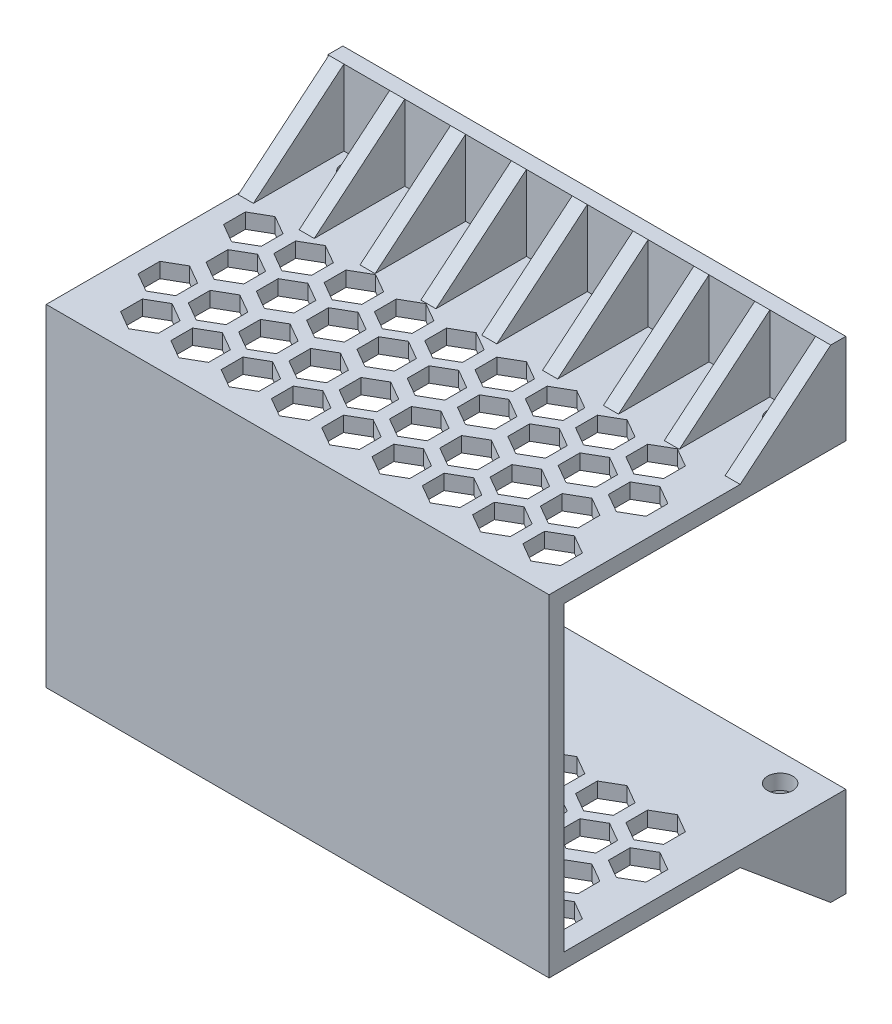
from build123d import *

# Parameters (mm, degrees)
SKETCH1_W                = 100
SKETCH1_H                = 60
BOSS_EXTRUDE1_DEPTH      = 3
SKETCH2_W                = 100
SKETCH2_H                = 3
BOSS_EXTRUDE2_DEPTH      = 53
BOSS_EXTRUDE2_DEPTH_BACK = 3
SKETCH3_W                = 100
SKETCH3_H                = 18
BOSS_EXTRUDE3_DEPTH      = 3
CUT_EXTRUDE1_DEPTH       = 82
BOSS_EXTRUDE4_DEPTH      = 3
SKETCH6_W                = 97
SKETCH6_H                = 18
BOSS_EXTRUDE5_DEPTH      = 3
LPATTERN4_COUNT          = 9
LPATTERN4_PITCH          = 12.1
SKETCH7_R                = 2.5
CUT_EXTRUDE2_DEPTH       = 82
SKETCH8_W                = 64.570177282
SKETCH8_H                = 59.777004532
CUT_EXTRUDE3_DEPTH       = 101


with BuildPart() as part:
    # Sketch1 → Boss-Extrude1 (new body)
    with BuildSketch(Plane.XY):
        with Locations((50, 30)):
            Rectangle(SKETCH1_W, SKETCH1_H)
    extrude(amount=BOSS_EXTRUDE1_DEPTH)

    # Sketch2 → Boss-Extrude2 (add, two sides)
    with BuildSketch(Plane(origin=(0, 0, 0), x_dir=(-1, 0, 0), z_dir=(0, 0, -1))) as boss_extrude2_sk:
        with Locations((-50, 61.5)):
            Rectangle(SKETCH2_W, SKETCH2_H)
        with Locations((-50, -1.5)):
            Rectangle(SKETCH2_W, SKETCH2_H)
    extrude(amount=BOSS_EXTRUDE2_DEPTH)
    extrude(boss_extrude2_sk.sketch, amount=-BOSS_EXTRUDE2_DEPTH_BACK)

    # Sketch3 → Boss-Extrude3 (add)
    with BuildSketch(Plane(origin=(0, 0, -53), x_dir=(-1, 0, 0), z_dir=(0, 0, -1))):
        with Locations((-50, 69)):
            Rectangle(SKETCH3_W, SKETCH3_H)
        with Locations((-50, -9)):
            Rectangle(SKETCH3_W, SKETCH3_H)
    extrude(amount=BOSS_EXTRUDE3_DEPTH)

    # Sketch4 → Cut-Extrude1 (cut, through all)
    with BuildSketch(Plane(origin=(0, 63, 0), x_dir=(1, 0, 0), z_dir=(0, 1, 0))):
        Polygon((91.375, 11.392304845), (91.375, 15.722431864), (87.625, 17.887495374), (83.875, 15.722431864), (83.875, 11.392304845), (87.625, 9.227241336), align=None)
        Polygon((96.125, 7.495190528), (92.375, 9.660254038), (88.625, 7.495190528), (88.625, 3.165063509), (92.375, 1), (96.125, 3.165063509), align=None)
        Polygon((81.375, 11.392304845), (81.375, 15.722431864), (77.625, 17.887495374), (73.875, 15.722431864), (73.875, 11.392304845), (77.625, 9.227241336), align=None)
        Polygon((86.125, 7.495190528), (82.375, 9.660254038), (78.625, 7.495190528), (78.625, 3.165063509), (82.375, 1), (86.125, 3.165063509), align=None)
        Polygon((71.375, 11.392304845), (71.375, 15.722431864), (67.625, 17.887495374), (63.875, 15.722431864), (63.875, 11.392304845), (67.625, 9.227241336), align=None)
        Polygon((76.125, 7.495190528), (72.375, 9.660254038), (68.625, 7.495190528), (68.625, 3.165063509), (72.375, 1), (76.125, 3.165063509), align=None)
        Polygon((61.375, 11.392304845), (61.375, 15.722431864), (57.625, 17.887495374), (53.875, 15.722431864), (53.875, 11.392304845), (57.625, 9.227241336), align=None)
        Polygon((66.125, 7.495190528), (62.375, 9.660254038), (58.625, 7.495190528), (58.625, 3.165063509), (62.375, 1), (66.125, 3.165063509), align=None)
        Polygon((51.375, 11.392304845), (51.375, 15.722431864), (47.625, 17.887495374), (43.875, 15.722431864), (43.875, 11.392304845), (47.625, 9.227241336), align=None)
        Polygon((56.125, 7.495190528), (52.375, 9.660254038), (48.625, 7.495190528), (48.625, 3.165063509), (52.375, 1), (56.125, 3.165063509), align=None)
        Polygon((41.375, 11.392304845), (41.375, 15.722431864), (37.625, 17.887495374), (33.875, 15.722431864), (33.875, 11.392304845), (37.625, 9.227241336), align=None)
        Polygon((46.125, 7.495190528), (42.375, 9.660254038), (38.625, 7.495190528), (38.625, 3.165063509), (42.375, 1), (46.125, 3.165063509), align=None)
        Polygon((31.375, 11.392304845), (31.375, 15.722431864), (27.625, 17.887495374), (23.875, 15.722431864), (23.875, 11.392304845), (27.625, 9.227241336), align=None)
        Polygon((36.125, 7.495190528), (32.375, 9.660254038), (28.625, 7.495190528), (28.625, 3.165063509), (32.375, 1), (36.125, 3.165063509), align=None)
        Polygon((21.375, 11.392304845), (21.375, 15.722431864), (17.625, 17.887495374), (13.875, 15.722431864), (13.875, 11.392304845), (17.625, 9.227241336), align=None)
        Polygon((26.125, 7.495190528), (22.375, 9.660254038), (18.625, 7.495190528), (18.625, 3.165063509), (22.375, 1), (26.125, 3.165063509), align=None)
        Polygon((11.375, 11.392304845), (11.375, 15.722431864), (7.625, 17.887495374), (3.875, 15.722431864), (3.875, 11.392304845), (7.625, 9.227241336), align=None)
        Polygon((16.125, 7.495190528), (12.375, 9.660254038), (8.625, 7.495190528), (8.625, 3.165063509), (12.375, 1), (16.125, 3.165063509), align=None)
        Polygon((81.375, 28.392304845), (81.375, 32.722431864), (77.625, 34.887495374), (73.875, 32.722431864), (73.875, 28.392304845), (77.625, 26.227241336), align=None)
        Polygon((86.125, 24.495190528), (82.375, 26.660254038), (78.625, 24.495190528), (78.625, 20.165063509), (82.375, 18), (86.125, 20.165063509), align=None)
        Polygon((71.375, 28.392304845), (71.375, 32.722431864), (67.625, 34.887495374), (63.875, 32.722431864), (63.875, 28.392304845), (67.625, 26.227241336), align=None)
        Polygon((76.125, 24.495190528), (72.375, 26.660254038), (68.625, 24.495190528), (68.625, 20.165063509), (72.375, 18), (76.125, 20.165063509), align=None)
        Polygon((61.375, 28.392304845), (61.375, 32.722431864), (57.625, 34.887495374), (53.875, 32.722431864), (53.875, 28.392304845), (57.625, 26.227241336), align=None)
        Polygon((66.125, 24.495190528), (62.375, 26.660254038), (58.625, 24.495190528), (58.625, 20.165063509), (62.375, 18), (66.125, 20.165063509), align=None)
        Polygon((51.375, 28.392304845), (51.375, 32.722431864), (47.625, 34.887495374), (43.875, 32.722431864), (43.875, 28.392304845), (47.625, 26.227241336), align=None)
        Polygon((56.125, 24.495190528), (52.375, 26.660254038), (48.625, 24.495190528), (48.625, 20.165063509), (52.375, 18), (56.125, 20.165063509), align=None)
        Polygon((41.375, 28.392304845), (41.375, 32.722431864), (37.625, 34.887495374), (33.875, 32.722431864), (33.875, 28.392304845), (37.625, 26.227241336), align=None)
        Polygon((46.125, 24.495190528), (42.375, 26.660254038), (38.625, 24.495190528), (38.625, 20.165063509), (42.375, 18), (46.125, 20.165063509), align=None)
        Polygon((31.375, 28.392304845), (31.375, 32.722431864), (27.625, 34.887495374), (23.875, 32.722431864), (23.875, 28.392304845), (27.625, 26.227241336), align=None)
        Polygon((36.125, 24.495190528), (32.375, 26.660254038), (28.625, 24.495190528), (28.625, 20.165063509), (32.375, 18), (36.125, 20.165063509), align=None)
        Polygon((21.375, 28.392304845), (21.375, 32.722431864), (17.625, 34.887495374), (13.875, 32.722431864), (13.875, 28.392304845), (17.625, 26.227241336), align=None)
        Polygon((26.125, 24.495190528), (22.375, 26.660254038), (18.625, 24.495190528), (18.625, 20.165063509), (22.375, 18), (26.125, 20.165063509), align=None)
        Polygon((11.375, 28.392304845), (11.375, 32.722431864), (7.625, 34.887495374), (3.875, 32.722431864), (3.875, 28.392304845), (7.625, 26.227241336), align=None)
        Polygon((16.125, 24.495190528), (12.375, 26.660254038), (8.625, 24.495190528), (8.625, 20.165063509), (12.375, 18), (16.125, 20.165063509), align=None)
        Polygon((81.375, 45.392304845), (81.375, 49.722431864), (77.625, 51.887495374), (73.875, 49.722431864), (73.875, 45.392304845), (77.625, 43.227241336), align=None)
        Polygon((86.125, 41.495190528), (82.375, 43.660254038), (78.625, 41.495190528), (78.625, 37.165063509), (82.375, 35), (86.125, 37.165063509), align=None)
        Polygon((71.375, 45.392304845), (71.375, 49.722431864), (67.625, 51.887495374), (63.875, 49.722431864), (63.875, 45.392304845), (67.625, 43.227241336), align=None)
        Polygon((76.125, 41.495190528), (72.375, 43.660254038), (68.625, 41.495190528), (68.625, 37.165063509), (72.375, 35), (76.125, 37.165063509), align=None)
        Polygon((61.375, 45.392304845), (61.375, 49.722431864), (57.625, 51.887495374), (53.875, 49.722431864), (53.875, 45.392304845), (57.625, 43.227241336), align=None)
        Polygon((66.125, 41.495190528), (62.375, 43.660254038), (58.625, 41.495190528), (58.625, 37.165063509), (62.375, 35), (66.125, 37.165063509), align=None)
        Polygon((51.375, 45.392304845), (51.375, 49.722431864), (47.625, 51.887495374), (43.875, 49.722431864), (43.875, 45.392304845), (47.625, 43.227241336), align=None)
        Polygon((56.125, 41.495190528), (52.375, 43.660254038), (48.625, 41.495190528), (48.625, 37.165063509), (52.375, 35), (56.125, 37.165063509), align=None)
        Polygon((41.375, 45.392304845), (41.375, 49.722431864), (37.625, 51.887495374), (33.875, 49.722431864), (33.875, 45.392304845), (37.625, 43.227241336), align=None)
        Polygon((46.125, 41.495190528), (42.375, 43.660254038), (38.625, 41.495190528), (38.625, 37.165063509), (42.375, 35), (46.125, 37.165063509), align=None)
        Polygon((31.375, 45.392304845), (31.375, 49.722431864), (27.625, 51.887495374), (23.875, 49.722431864), (23.875, 45.392304845), (27.625, 43.227241336), align=None)
        Polygon((36.125, 41.495190528), (32.375, 43.660254038), (28.625, 41.495190528), (28.625, 37.165063509), (32.375, 35), (36.125, 37.165063509), align=None)
        Polygon((21.375, 45.392304845), (21.375, 49.722431864), (17.625, 51.887495374), (13.875, 49.722431864), (13.875, 45.392304845), (17.625, 43.227241336), align=None)
        Polygon((26.125, 41.495190528), (22.375, 43.660254038), (18.625, 41.495190528), (18.625, 37.165063509), (22.375, 35), (26.125, 37.165063509), align=None)
        Polygon((11.375, 45.392304845), (11.375, 49.722431864), (7.625, 51.887495374), (3.875, 49.722431864), (3.875, 45.392304845), (7.625, 43.227241336), align=None)
        Polygon((16.125, 41.495190528), (12.375, 43.660254038), (8.625, 41.495190528), (8.625, 37.165063509), (12.375, 35), (16.125, 37.165063509), align=None)
        Polygon((91.375, 28.392304845), (91.375, 32.722431864), (87.625, 34.887495374), (83.875, 32.722431864), (83.875, 28.392304845), (87.625, 26.227241336), align=None)
        Polygon((96.125, 24.495190528), (92.375, 26.660254038), (88.625, 24.495190528), (88.625, 20.165063509), (92.375, 18), (96.125, 20.165063509), align=None)
        Polygon((91.375, 45.392304845), (91.375, 49.722431864), (87.625, 51.887495374), (83.875, 49.722431864), (83.875, 45.392304845), (87.625, 43.227241336), align=None)
        Polygon((96.125, 41.495190528), (92.375, 43.660254038), (88.625, 41.495190528), (88.625, 37.165063509), (92.375, 35), (96.125, 37.165063509), align=None)
    extrude(amount=-CUT_EXTRUDE1_DEPTH, mode=Mode.SUBTRACT)

    # Sketch5 → Boss-Extrude4 (add)
    with BuildSketch(Plane(origin=(100, 0, 0), x_dir=(0, 0, -1), z_dir=(1, 0, 0))):
        Polygon((35, -3), (53, -3), (53, -18), align=None)
    boss_extrude4 = extrude(amount=-BOSS_EXTRUDE4_DEPTH)

    # Sketch6 → Boss-Extrude5 (add)
    with BuildSketch(Plane.XZ.offset(3)):
        with Locations((48.5, -44)):
            Rectangle(SKETCH6_W, SKETCH6_H)
    extrude(amount=-BOSS_EXTRUDE5_DEPTH)

    # LPattern4: Boss-Extrude4 ×9
    with Locations(*[(-i * LPATTERN4_PITCH, 0, 0) for i in range(1, LPATTERN4_COUNT)]):
        add(boss_extrude4)

    # Sketch7 → Cut-Extrude2 (cut, through all)
    with BuildSketch(Plane.XZ.offset(3)):
        with Locations((92.45, -50.5)):
            Circle(SKETCH7_R)
        with Locations((7.75, -50.5)):
            Circle(SKETCH7_R)
    extrude(amount=-CUT_EXTRUDE2_DEPTH, mode=Mode.SUBTRACT)

    # Sketch8 → Cut-Extrude3 (cut, through all)
    with BuildSketch(Plane(origin=(100, 0, 0), x_dir=(0, 0, -1), z_dir=(1, 0, 0))):
        with Locations((29.285088641, 59.888502266)):
            Rectangle(SKETCH8_W, SKETCH8_H)
    extrude(amount=-CUT_EXTRUDE3_DEPTH, mode=Mode.SUBTRACT)

    # Mirror1: part across plane


with BuildPart() as part_1:
    add(part.part)
    add(part.part.mirror(Plane(origin=(0, 30, 3), x_dir=(0, 0, 1), z_dir=(0, -1, 0))))


solid = part_1.part
